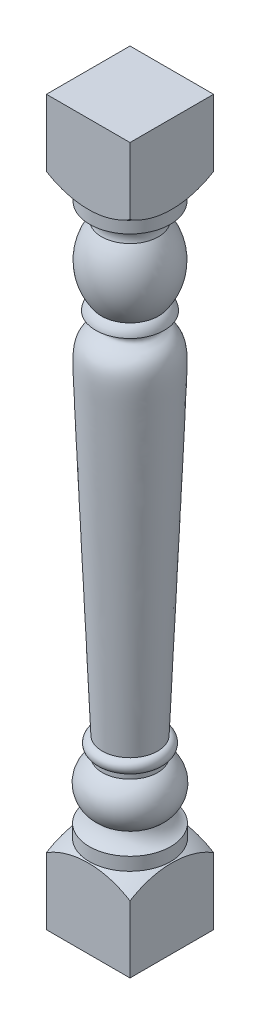
from build123d import *

# Parameters (mm, degrees)
SKETCH4_OUTSIDE_W       = 568.745
SKETCH4_OUTSIDE_H       = 568.744
SKETCH4_OUTSIDE_W_2     = 142.875
SKETCH4_OUTSIDE_H_2     = 142.875
CUT_EXTRUDE2_DEPTH      = 1102.137097563
CUT_EXTRUDE2_DEPTH_BACK = 136.613389618


with BuildPart() as part:
    # Sketch2 → Revolve2 (revolve)
    with BuildSketch(Plane.XY):
        with BuildLine():
            Line((0, -135.613389618), (71.4375, -135.613389618))
            Line((71.4375, -135.613389618), (71.4375, 1101.137097563))
            Line((71.4375, 1101.137097563), (0, 1101.137097563))
            Line((0, 1101.137097563), (-80.9625, 1101.137097563))
            ThreePointArc((-80.9625, 1101.137097563), (-58.419611858, 1021.369369126), (2.54, 965.2))
            Line((2.54, 965.2), (2.54, 942.975))
            ThreePointArc((2.54, 942.975), (19.833806838, 933.760429307), (22.86, 914.4))
            ThreePointArc((22.86, 914.4), (2.54, 855.6625), (22.86, 796.925))
            ThreePointArc((22.86, 796.925), (16.116640845, 790.052049859), (12.7, 781.05))
            add(Edge.make_bspline(
                [(12.7, 781.05), (28.543276087, 778.212494125), (43.256272949, 750.690215213), (-0.0352258, 758.012837994), (6.586319301, 584.753689168), (4.683111774, 626.517341683), (24.13, 152.4)],
                knots=[0, 0, 0, 0, 0.11708426, 0.342939455, 0.431231029, 1, 1, 1, 1], degree=3))
            ThreePointArc((24.13, 152.4), (13.97, 141.2875), (24.13, 130.175))
            Line((24.13, 130.175), (24.13, 120.65))
            ThreePointArc((24.13, 120.65), (1.440144638, 82.917580923), (22.86, 44.45))
            ThreePointArc((22.86, 44.45), (14.760476333, 31.095408029), (1.905, 22.225))
            Line((1.905, 22.225), (1.905, 0))
            ThreePointArc((1.905, 0), (-58.605787024, -56.149539347), (-80.9625, -135.613389618))
            Line((-80.9625, -135.613389618), (0, -135.613389618))
        make_face()
    revolve(axis=Axis((71.4375, -135.613389618, 0), (0, 1, 0)))

    # Sketch4 outside → Cut-Extrude2 (cut, two sides)
    with BuildSketch(Plane(origin=(0, 0, 0), x_dir=(1, 0, 0), z_dir=(0, 1, 0))) as cut_extrude2_sk:
        with Locations((71.4375, 0)):
            Rectangle(SKETCH4_OUTSIDE_W, SKETCH4_OUTSIDE_H)
        with Locations((71.4375, 0)):
            Rectangle(SKETCH4_OUTSIDE_W_2, SKETCH4_OUTSIDE_H_2, mode=Mode.SUBTRACT)
    extrude(amount=CUT_EXTRUDE2_DEPTH, mode=Mode.SUBTRACT)
    extrude(cut_extrude2_sk.sketch, amount=-CUT_EXTRUDE2_DEPTH_BACK, mode=Mode.SUBTRACT)


solid = part.part
